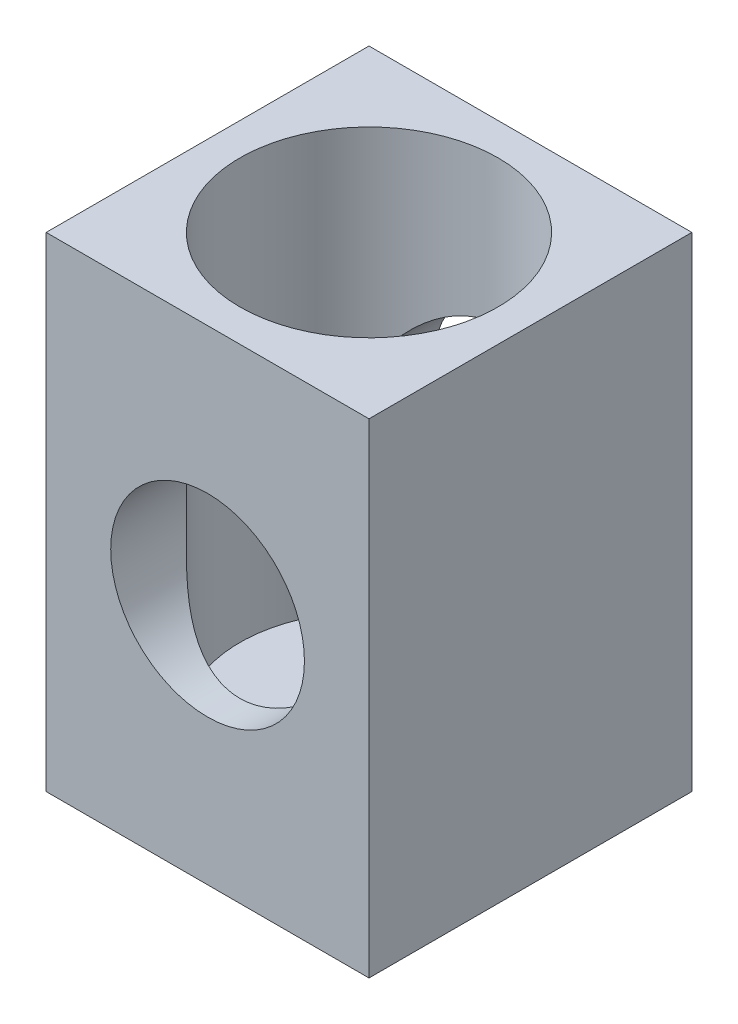
from build123d import *

# Parameters (mm, degrees)
SKETCH1_W           = 10
SKETCH1_H           = 15
SKETCH1_R           = 3
BOSS_EXTRUDE1_DEPTH = 10
SKETCH3_R           = 4
CUT_EXTRUDE1_DEPTH  = 13


with BuildPart() as part:
    # Sketch1 → Boss-Extrude1 (new body)
    with BuildSketch(Plane.XY):
        Rectangle(SKETCH1_W, SKETCH1_H)
        Circle(SKETCH1_R, mode=Mode.SUBTRACT)
    extrude(amount=BOSS_EXTRUDE1_DEPTH)

    # Sketch3 → Cut-Extrude1 (cut)
    with BuildSketch(Plane(origin=(0, 7.5, 0), x_dir=(1, 0, 0), z_dir=(0, 1, 0))):
        with Locations((0, -5)):
            Circle(SKETCH3_R)
    extrude(amount=-CUT_EXTRUDE1_DEPTH, mode=Mode.SUBTRACT)


solid = part.part
